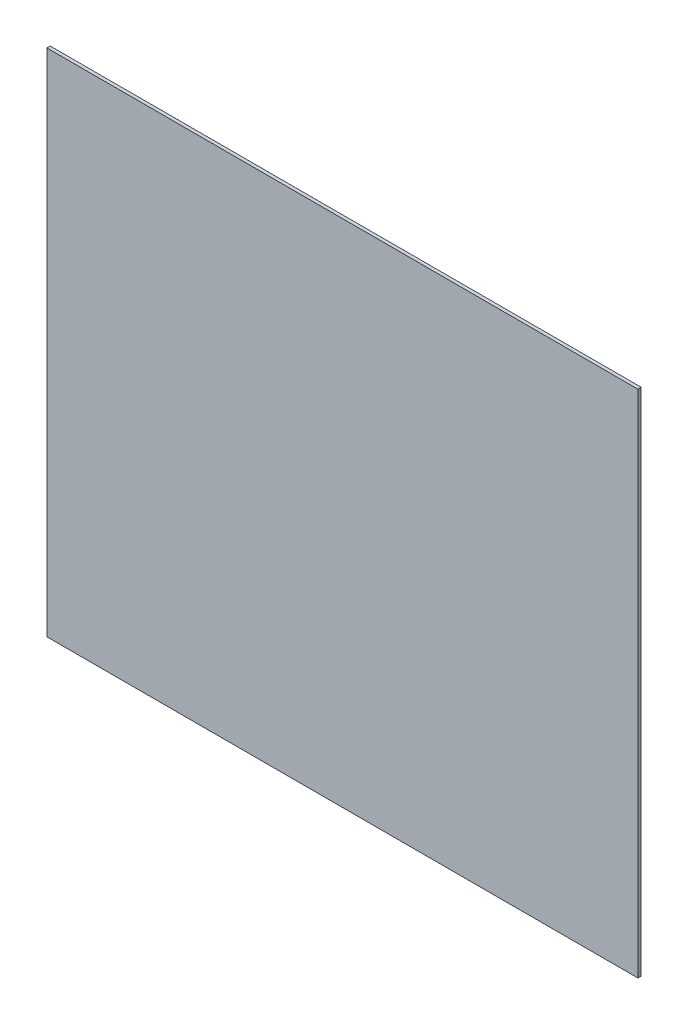
from build123d import *

# Parameters (mm, degrees)
ESQUISSE1_W        = 540
ESQUISSE1_H        = 466
BOSS_EXTRU_1_DEPTH = 3


with BuildPart() as part:
    # Esquisse1 → Boss.-Extru.1 (new body)
    with BuildSketch(Plane.XY):
        with Locations((202.880321282, -202.747507129)):
            Rectangle(ESQUISSE1_W, ESQUISSE1_H)
    extrude(amount=BOSS_EXTRU_1_DEPTH)


solid = part.part
